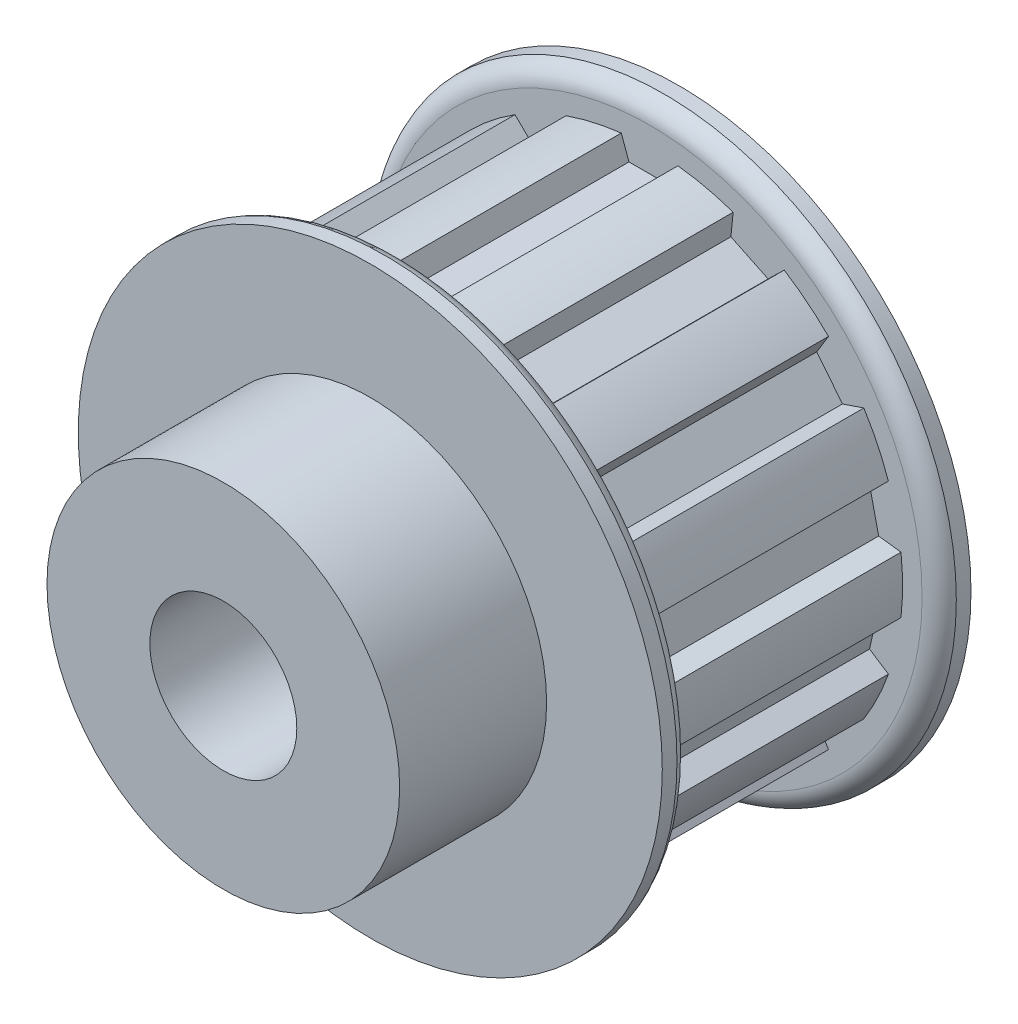
from build123d import *

# Parameters (mm, degrees)
CUT_EXTRUDE1_START = 5.5626
CUT_EXTRUDE1_DEPTH = 27.0002
CIRPATTERN1_COUNT  = 14


with BuildPart() as part:
    # Sketch2 → Revolve1 (revolve)
    with BuildSketch(Plane(origin=(0, 0, 0), x_dir=(0, 0, -1), z_dir=(1, 0, 0))):
        with BuildLine():
            Line((-24.6126, 7.9375), (24.6126, 7.9375))
            Line((24.6126, 7.9375), (24.6126, 31.5468))
            Line((24.6126, 31.5468), (23.0251, 31.5468))
            ThreePointArc((23.0251, 31.5468), (21.87887746, 30.758520647), (21.4376, 29.439246357))
            Line((21.4376, 29.439246357), (21.4376, 27.331692713))
            Line((21.4376, 27.331692713), (-5.5626, 27.331692713))
            Line((-5.5626, 27.331692713), (-5.5626, 29.439246357))
            ThreePointArc((-5.5626, 29.439246357), (-6.00387746, 30.758520647), (-7.1501, 31.5468))
            Line((-7.1501, 31.5468), (-8.7376, 31.5468))
            Line((-8.7376, 31.5468), (-8.7376, 19.05))
            Line((-8.7376, 19.05), (-24.6126, 19.05))
            Line((-24.6126, 19.05), (-24.6126, 7.9375))
        make_face()
    revolve(axis=Axis((0, 0, 24.6126), (0, 0, -1)))

    # Sketch3 → Cut-Extrude1 (cut)
    with BuildSketch(Plane.XY.offset(CUT_EXTRUDE1_START)):
        with BuildLine():
            Line((-2.228664044, 24.87377802), (2.228664044, 24.87377802))
            Line((2.228664044, 24.87377802), (3.0607, 27.15977802))
            ThreePointArc((3.0607, 27.15977802), (0, 27.331692713), (-3.0607, 27.15977802))
            Line((-3.0607, 27.15977802), (-2.228664044, 24.87377802))
        make_face()
    cut_extrude1 = extrude(amount=-CUT_EXTRUDE1_DEPTH, mode=Mode.SUBTRACT)

    # CirPattern1: Cut-Extrude1 ×14 about axis
    cirpattern1_axis = Axis((0, 0, 0), (0, 0, 1))
    for i in range(1, CIRPATTERN1_COUNT):
        add(cut_extrude1.rotate(cirpattern1_axis, i * 360 / CIRPATTERN1_COUNT), mode=Mode.SUBTRACT)


solid = part.part
